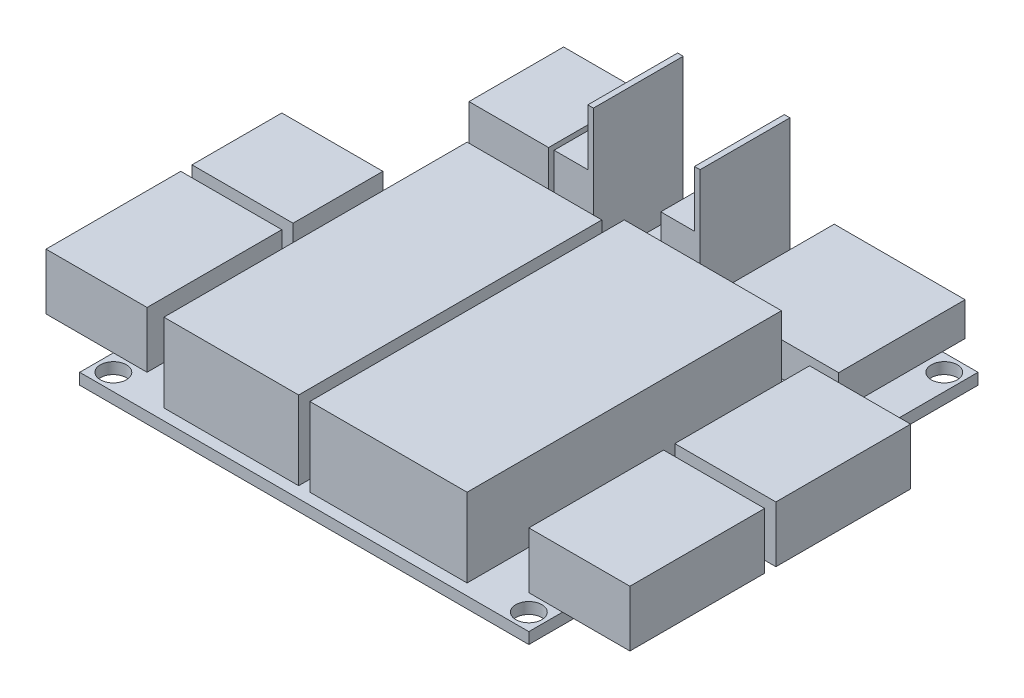
from build123d import *

# Parameters (mm, degrees)
SKETCH5_W           = 50.8
SKETCH5_H           = 50.8
BOSS_EXTRUDE1_DEPTH = 1.27
SKETCH6_W           = 11.43
SKETCH6_H           = 10.16
SKETCH6_H_2         = 15.24
BOSS_EXTRUDE2_DEPTH = 6.35
SKETCH7_W           = 15.24
SKETCH7_H           = 34.29
SKETCH7_W_2         = 17.78
SKETCH7_H_2         = 35.56
BOSS_EXTRUDE3_DEPTH = 8.89
SKETCH8_R           = 1.4732
CUT_EXTRUDE1_DEPTH  = 2.27
SKETCH9_W           = 4.445
SKETCH9_H           = 10.16
BOSS_EXTRUDE4_DEPTH = 8.89
SKETCH11_W          = 0.635
SKETCH11_H          = 10.16
BOSS_EXTRUDE5_DEPTH = 6.35
SKETCH12_W          = 8.999982
SKETCH12_H          = 10.700004
BOSS_EXTRUDE6_DEPTH = 8.89
SKETCH13_W          = 14.8000212
SKETCH13_H          = 14.2999968
BOSS_EXTRUDE7_DEPTH = 3.81
SKETCH17_R          = 2.5
CUT_EXTRUDE2_DEPTH  = 6.35


with BuildPart() as part:
    # Sketch5 → Boss-Extrude1 (new body)
    with BuildSketch(Plane(origin=(0, 0, 0), x_dir=(1, 0, 0), z_dir=(0, 1, 0))):
        with Locations((25.4, 25.4)):
            Rectangle(SKETCH5_W, SKETCH5_H)
    extrude(amount=-BOSS_EXTRUDE1_DEPTH)

    # Sketch6 → Boss-Extrude2 (add)
    with BuildSketch(Plane(origin=(0, 0, 0), x_dir=(1, 0, 0), z_dir=(0, 1, 0))):
        with Locations((-1.905, 25.4)):
            Rectangle(SKETCH6_W, SKETCH6_H)
        with Locations((-1.905, 11.43)):
            Rectangle(SKETCH6_W, SKETCH6_H_2)
        with Locations((52.705, 27.94)):
            Rectangle(SKETCH6_W, SKETCH6_H_2)
        with Locations((52.705, 11.43)):
            Rectangle(SKETCH6_W, SKETCH6_H_2)
    extrude(amount=BOSS_EXTRUDE2_DEPTH)

    # Sketch7 → Boss-Extrude3 (add)
    with BuildSketch(Plane(origin=(0, 0, 0), x_dir=(1, 0, 0), z_dir=(0, 1, 0))):
        with Locations((15.875, 18.415)):
            Rectangle(SKETCH7_W, SKETCH7_H)
        with Locations((33.655, 19.05)):
            Rectangle(SKETCH7_W_2, SKETCH7_H_2)
    extrude(amount=BOSS_EXTRUDE3_DEPTH)

    # Sketch8 → Cut-Extrude1 (cut, through all)
    with BuildSketch(Plane(origin=(0, 0, 0), x_dir=(1, 0, 0), z_dir=(0, 1, 0))):
        with Locations((1.905, 48.895)):
            Circle(SKETCH8_R)
        with Locations((48.895, 48.895)):
            Circle(SKETCH8_R)
        with Locations((1.905, 1.905)):
            Circle(SKETCH8_R)
        with Locations((48.895, 1.905)):
            Circle(SKETCH8_R)
    extrude(amount=-CUT_EXTRUDE1_DEPTH, mode=Mode.SUBTRACT)

    # Sketch9 → Boss-Extrude4 (add)
    with BuildSketch(Plane(origin=(0, 0, 0), x_dir=(1, 0, 0), z_dir=(0, 1, 0))):
        with Locations((28.2575, 44.7675)):
            Rectangle(SKETCH9_W, SKETCH9_H)
        with Locations((16.1925, 44.7675)):
            Rectangle(SKETCH9_W, SKETCH9_H)
    extrude(amount=BOSS_EXTRUDE4_DEPTH)

    # Sketch11 → Boss-Extrude5 (add)
    with BuildSketch(Plane(origin=(0, 8.89, 0), x_dir=(1, 0, 0), z_dir=(0, 1, 0))):
        with Locations((30.1625, 44.7675)):
            Rectangle(SKETCH11_W, SKETCH11_H)
        with Locations((18.0975, 44.7675)):
            Rectangle(SKETCH11_W, SKETCH11_H)
    extrude(amount=BOSS_EXTRUDE5_DEPTH)

    # Sketch12 → Boss-Extrude6 (add)
    with BuildSketch(Plane(origin=(0, 0, 0), x_dir=(1, 0, 0), z_dir=(0, 1, 0))):
        with Locations((8.89, 44.990004)):
            Rectangle(SKETCH12_W, SKETCH12_H)
    extrude(amount=BOSS_EXTRUDE6_DEPTH)

    # Sketch13 → Boss-Extrude7 (add)
    with BuildSketch(Plane(origin=(0, 0, 0), x_dir=(1, 0, 0), z_dir=(0, 1, 0))):
        with Locations((39.37, 46.219999)):
            Rectangle(SKETCH13_W, SKETCH13_H)
    extrude(amount=BOSS_EXTRUDE7_DEPTH)

    # Sketch17 → Cut-Extrude2 (cut)
    with BuildSketch(Plane(origin=(0, 0, -50.340006), x_dir=(-1, 0, 0), z_dir=(0, 0, -1))):
        with Locations((-8.89, 5.916248933)):
            Circle(SKETCH17_R)
    extrude(amount=-CUT_EXTRUDE2_DEPTH, mode=Mode.SUBTRACT)


solid = part.part
